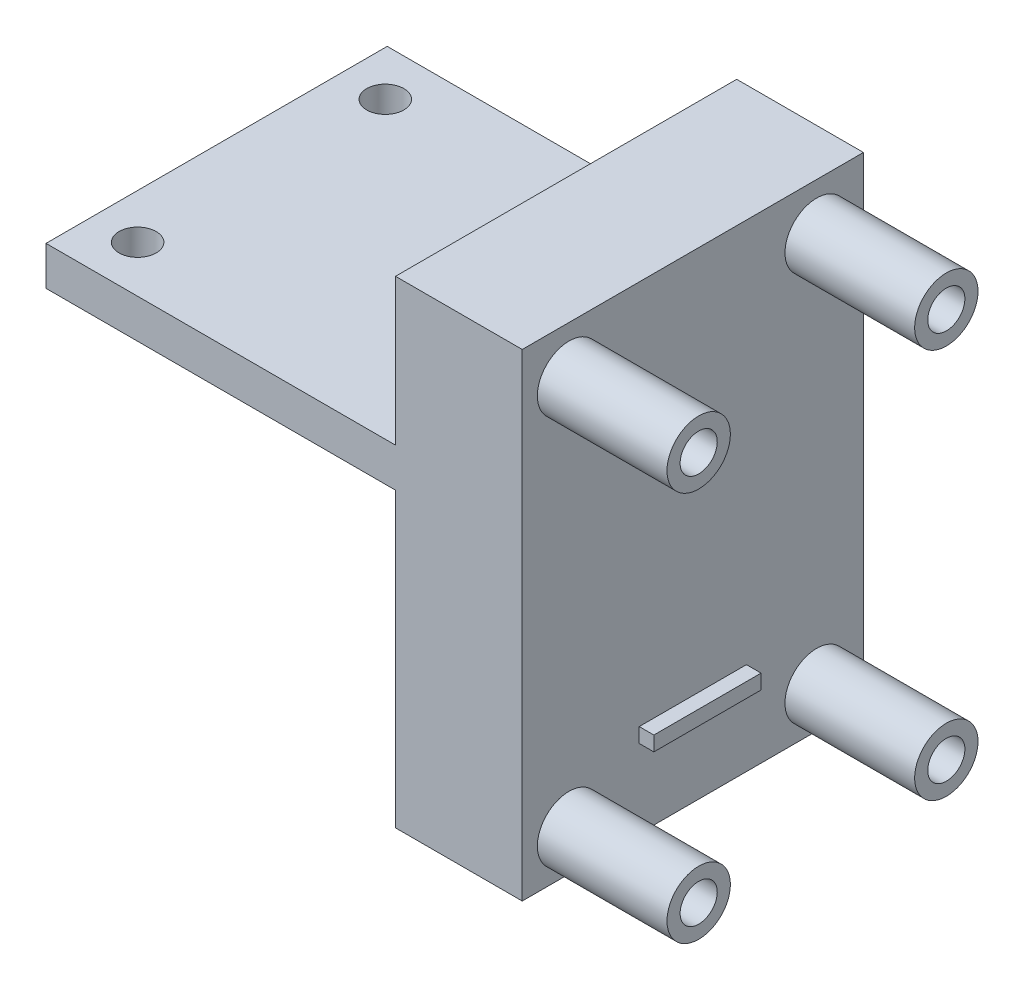
from build123d import *

# Parameters (mm, degrees)
BOSS_EXTRUDE1_DEPTH = 35
SKETCH5_R           = 1.905
CUT_EXTRUDE1_DEPTH  = 35
SKETCH2_R           = 1.905
CUT_EXTRUDE2_DEPTH  = 49.85
SKETCH7_W           = 11
SKETCH7_H           = 1.5
BOSS_EXTRUDE3_DEPTH = 1.5
SKETCH8_R           = 1.905
CUT_EXTRUDE3_DEPTH  = 49.85
SKETCH11_R          = 3.25
SKETCH11_R_2        = 1.905
BOSS_EXTRUDE4_DEPTH = 13.3


with BuildPart() as part:
    # Sketch1 → Boss-Extrude1 (new body)
    with BuildSketch(Plane.XY):
        Polygon((0, 0), (13, 0), (13, 34), (13, 49), (0, 49), (0, 34), (-35.85, 34), (-35.85, 30), (0, 30), align=None)
    extrude(amount=-BOSS_EXTRUDE1_DEPTH)

    # Sketch5 → Cut-Extrude1 (cut, through all)
    with BuildSketch(Plane(origin=(0, 34, 0), x_dir=(1, 0, 0), z_dir=(0, 1, 0))):
        with Locations((-31.25, 4.8)):
            Circle(SKETCH5_R)
        with Locations((-31.25, 30.2)):
            Circle(SKETCH5_R)
    extrude(amount=-CUT_EXTRUDE1_DEPTH, mode=Mode.SUBTRACT)

    # Sketch2 → Cut-Extrude2 (cut, through all)
    with BuildSketch(Plane(origin=(13, 0, 0), x_dir=(0, 0, -1), z_dir=(1, 0, 0))):
        with Locations((4.8, 4.1)):
            Circle(SKETCH2_R)
        with Locations((30.2, 4.1)):
            Circle(SKETCH2_R)
    extrude(amount=-CUT_EXTRUDE2_DEPTH, mode=Mode.SUBTRACT)

    # Sketch7 → Boss-Extrude3 (add)
    with BuildSketch(Plane(origin=(13, 0, 0), x_dir=(0, 0, -1), z_dir=(1, 0, 0))):
        with Locations((17.5, 8.75)):
            Rectangle(SKETCH7_W, SKETCH7_H)
    extrude(amount=BOSS_EXTRUDE3_DEPTH)

    # Sketch8 → Cut-Extrude3 (cut, through all)
    with BuildSketch(Plane(origin=(13, 0, 0), x_dir=(0, 0, -1), z_dir=(1, 0, 0))):
        with Locations((4.8, 44.1)):
            Circle(SKETCH8_R)
        with Locations((30.2, 44.1)):
            Circle(SKETCH8_R)
    extrude(amount=-CUT_EXTRUDE3_DEPTH, mode=Mode.SUBTRACT)

    # Sketch11 → Boss-Extrude4 (add)
    with BuildSketch(Plane(origin=(13, 0, 0), x_dir=(0, 0, -1), z_dir=(1, 0, 0))):
        with Locations((4.8, 44.1)):
            Circle(SKETCH11_R)
        with Locations((4.8, 44.1)):
            Circle(SKETCH11_R_2, mode=Mode.SUBTRACT)
        with Locations((30.2, 44.1)):
            Circle(SKETCH11_R)
        with Locations((30.2, 44.1)):
            Circle(SKETCH11_R_2, mode=Mode.SUBTRACT)
        with Locations((30.2, 4.1)):
            Circle(SKETCH11_R)
        with Locations((30.2, 4.1)):
            Circle(SKETCH11_R_2, mode=Mode.SUBTRACT)
        with Locations((4.8, 4.1)):
            Circle(SKETCH11_R)
        with Locations((4.8, 4.1)):
            Circle(SKETCH11_R_2, mode=Mode.SUBTRACT)
    extrude(amount=BOSS_EXTRUDE4_DEPTH)


solid = part.part
